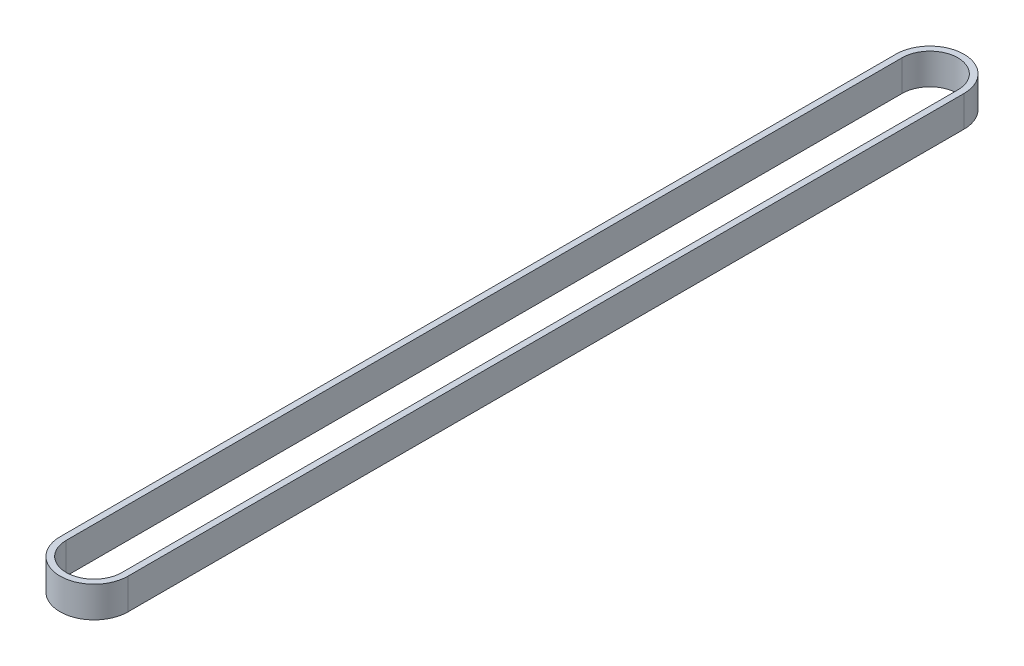
from build123d import *

# Parameters (mm, degrees)
BOSS_EXTRUDE1_DEPTH = 10


with BuildPart() as part:
    # Sketch1 → Boss-Extrude1 (new body)
    with BuildSketch(Plane(origin=(0, 0, 0), x_dir=(1, 0, 0), z_dir=(0, 1, 0))):
        with BuildLine():
            Line((-11, -270), (-11, 0))
            ThreePointArc((-11, 0), (0, 11), (11, 0))
            Line((11, 0), (11, -270))
            ThreePointArc((11, -270), (0, -281), (-11, -270))
        make_face()
        with BuildLine():
            Line((-9, -270), (-9, 0))
            ThreePointArc((-9, 0), (0, 9), (9, 0))
            Line((9, 0), (9, -270))
            ThreePointArc((9, -270), (0, -279), (-9, -270))
        make_face(mode=Mode.SUBTRACT)
    extrude(amount=BOSS_EXTRUDE1_DEPTH)


solid = part.part
